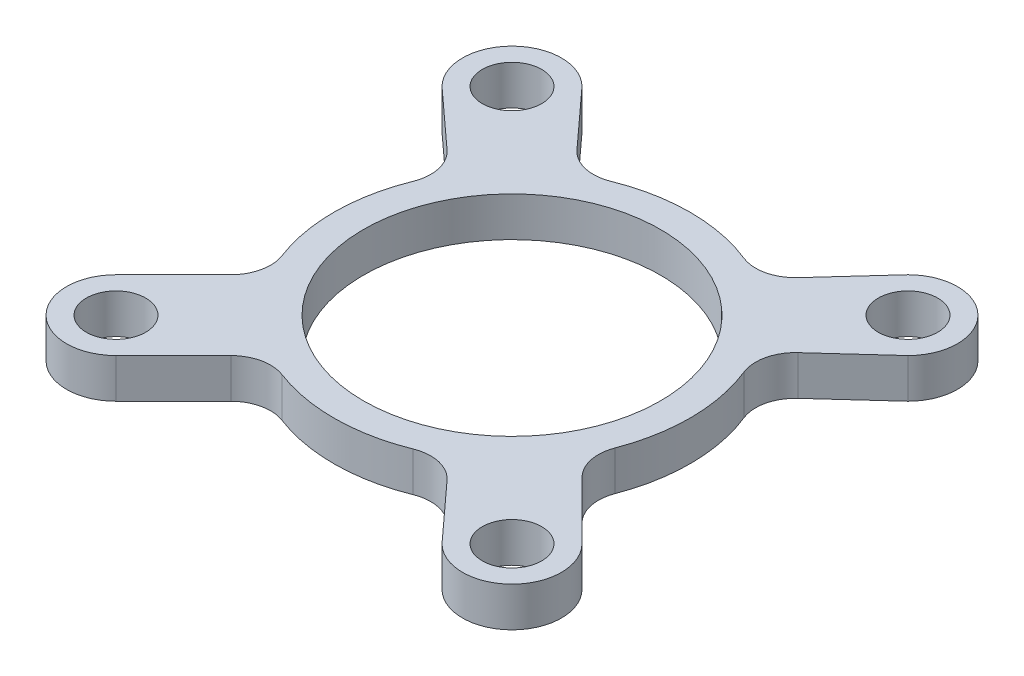
from build123d import *

# Parameters (mm, degrees)
SKETCH1_R           = 7.5
SKETCH1_R_2         = 1.5
BOSS_EXTRUDE1_DEPTH = 2
FILLET1_R           = 2


with BuildPart() as part:
    # Sketch1 → Boss-Extrude1 (new body)
    with BuildSketch(Plane(origin=(0, 0, 0), x_dir=(1, 0, 0), z_dir=(0, 1, 0))):
        with BuildLine():
            Line((-11.767766953, -8.232233047), (-7.881276583, -4.345742677))
            ThreePointArc((-7.881276583, -4.345742677), (-8.999066908, 0.129594703), (-7.75286903, 4.570888514))
            Line((-7.75286903, 4.570888514), (-11.767766953, 8.232233047))
            ThreePointArc((-11.767766953, 8.232233047), (-11.767766953, 11.767766953), (-8.232233047, 11.767766953))
            Line((-8.232233047, 11.767766953), (-4.570888514, 7.75286903))
            ThreePointArc((-4.570888514, 7.75286903), (0, 9), (4.570888514, 7.75286903))
            Line((4.570888514, 7.75286903), (8.232233047, 11.767766953))
            ThreePointArc((8.232233047, 11.767766953), (11.767766953, 11.767766953), (11.767766953, 8.232233047))
            Line((11.767766953, 8.232233047), (7.75286903, 4.570888514))
            ThreePointArc((7.75286903, 4.570888514), (8.999066908, 0.129594703), (7.881276583, -4.345742677))
            Line((7.881276583, -4.345742677), (11.767766953, -8.232233047))
            ThreePointArc((11.767766953, -8.232233047), (11.767766953, -11.767766953), (8.232233047, -11.767766953))
            Line((8.232233047, -11.767766953), (4.570888514, -7.75286903))
            ThreePointArc((4.570888514, -7.75286903), (0.129594703, -8.999066908), (-4.345742677, -7.881276583))
            Line((-4.345742677, -7.881276583), (-8.232233047, -11.767766953))
            ThreePointArc((-8.232233047, -11.767766953), (-11.767766953, -11.767766953), (-11.767766953, -8.232233047))
        make_face()
        Circle(SKETCH1_R, mode=Mode.SUBTRACT)
        with Locations((-10, -10)):
            Circle(SKETCH1_R_2, mode=Mode.SUBTRACT)
        with Locations((10, -10)):
            Circle(SKETCH1_R_2, mode=Mode.SUBTRACT)
        with Locations((10, 10)):
            Circle(SKETCH1_R_2, mode=Mode.SUBTRACT)
        with Locations((-10, 10)):
            Circle(SKETCH1_R_2, mode=Mode.SUBTRACT)
    extrude(amount=BOSS_EXTRUDE1_DEPTH)

    # Fillet1
    fillet1_edges = [part.edges().sort_by_distance(p)[0] for p in [
        (-7.881276583, 1, 4.345742677),
        (-7.75286903, 1, -4.570888514),
        (-4.570888514, 1, -7.75286903),
        (4.570888514, 1, -7.75286903),
        (7.75286903, 1, -4.570888514),
        (7.881276583, 1, 4.345742677),
        (4.570888514, 1, 7.75286903),
        (-4.345742677, 1, 7.881276583),
    ]]
    fillet(fillet1_edges, radius=FILLET1_R)


solid = part.part
